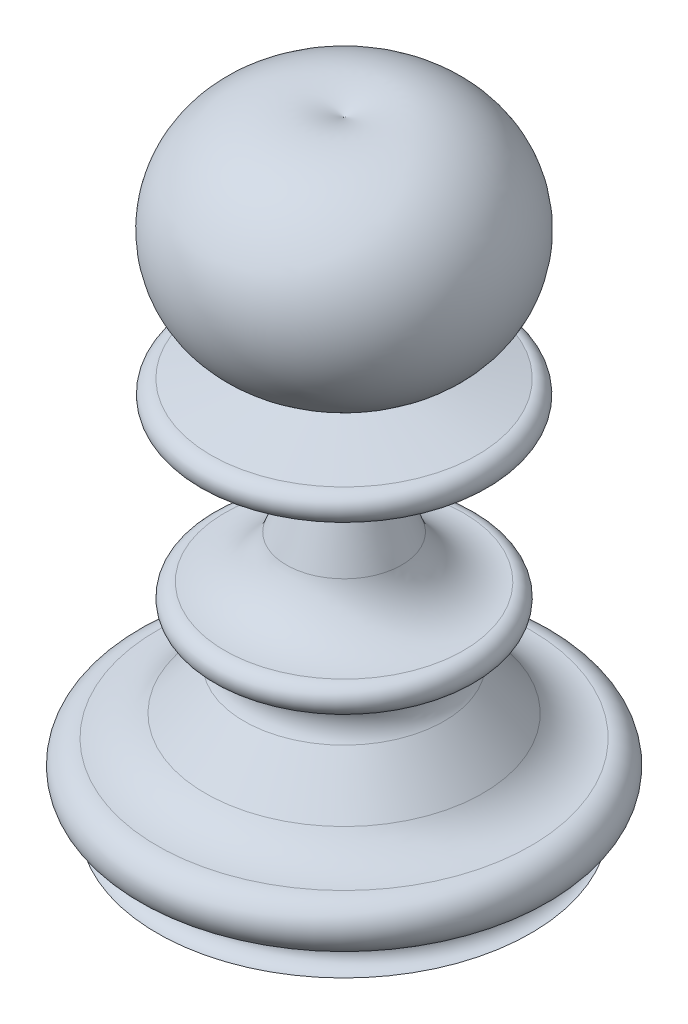
from build123d import *


with BuildPart() as part:
    # Sketch1 → Revolve1 (revolve)
    with BuildSketch(Plane.XY, mode=Mode.PRIVATE) as revolve1_sk:
        with BuildLine():
            Line((0, 0), (-21.024275398, 0))
            ThreePointArc((-21.024275398, 0), (-19.437537632, 1.586737766), (-21.024275398, 3.173475532))
            ThreePointArc((-21.024275398, 3.173475532), (-23.701895377, 5.851095512), (-21.024275398, 8.528715491))
            ThreePointArc((-21.024275398, 8.528715491), (-18.063147102, 9.159373756), (-15.615973742, 10.94188692))
            Line((-15.615973742, 10.94188692), (-11.259738919, 15.795734055))
            ThreePointArc((-11.259738919, 15.795734055), (-10.765155576, 18.943105474), (-13.43785633, 20.677242207))
            ThreePointArc((-13.43785633, 20.677242207), (-14.985609172, 22.224995049), (-13.43785633, 23.77274789))
            ThreePointArc((-13.43785633, 23.77274789), (-9.193768404, 25.108072488), (-6.478845476, 28.6329225))
            Line((-6.478845476, 28.6329225), (-4.700386203, 33.482536837))
            Line((-4.700386203, 33.482536837), (-4.700386203, 40.491748547))
            Line((-4.700386203, 40.491748547), (-14.985609172, 40.491748547))
            ThreePointArc((-14.985609172, 40.491748547), (-16.540865047, 42.047004422), (-14.985609172, 43.602260297))
            Line((-14.985609172, 43.602260297), (-2.07069837, 46.509062417))
            ThreePointArc((-2.07069837, 46.509062417), (-16.540945966, 59.212487458), (0, 69.069575252))
            Line((0, 69.069575252), (0, 0))
        make_face()
    revolve(revolve1_sk.sketch.rotate(Axis((0, 0, 0), (0, 1, 0)), 270), axis=Axis((0, 0, 0), (0, 1, 0)))  # turned: the seam where the file's is


solid = part.part
